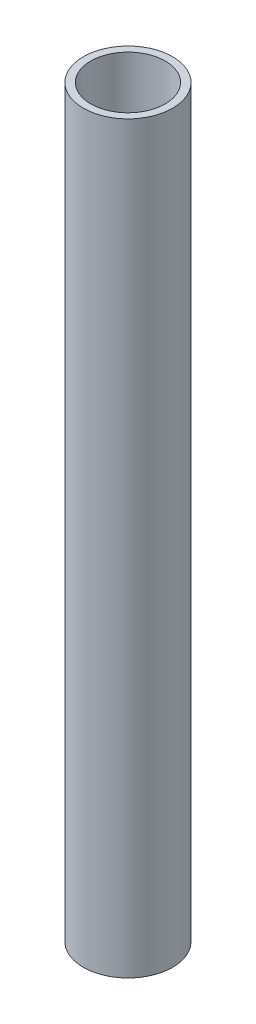
from build123d import *

# Parameters (mm, degrees)
SKETCH1_R           = 3
SKETCH1_R_2         = 2.5
BOSS_EXTRUDE1_DEPTH = 50


with BuildPart() as part:
    # Sketch1 → Boss-Extrude1 (new body)
    with BuildSketch(Plane(origin=(0, 0, 0), x_dir=(1, 0, 0), z_dir=(0, 1, 0))):
        Circle(SKETCH1_R)
        Circle(SKETCH1_R_2, mode=Mode.SUBTRACT)
    extrude(amount=BOSS_EXTRUDE1_DEPTH)


solid = part.part
